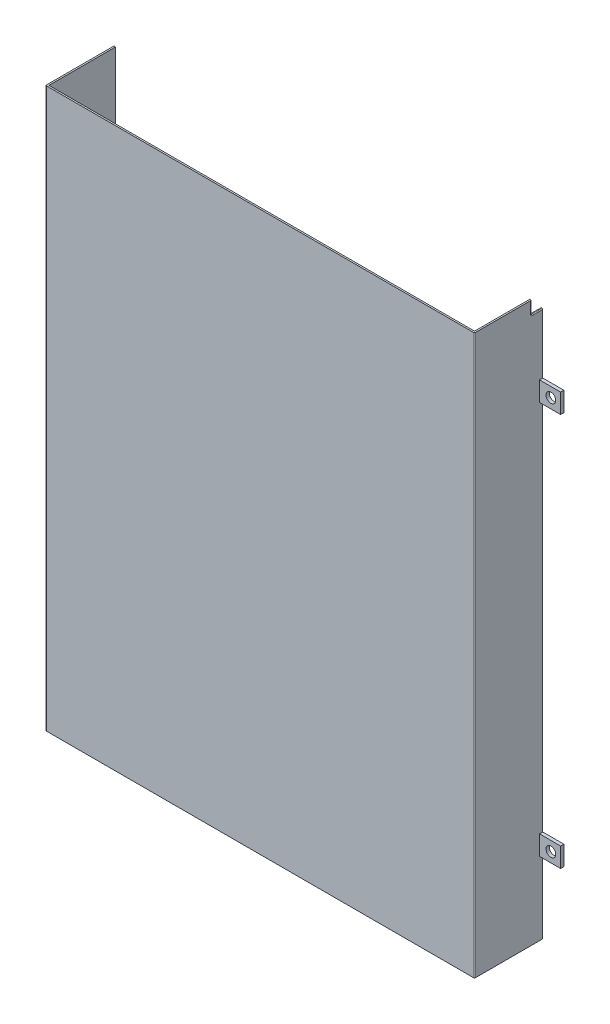
from build123d import *

# Parameters (mm, degrees)
WYCI_GNI_CIE_CIENKA_CIANKA1_DEPTH      = 172
WYCI_GNI_CIE_CIENKA_CIANKA1_DEPTH_BACK = 172
SZKIC2_W                               = 13
SZKIC2_H                               = 12
SZKIC2_R                               = 3
DODANIE_WYCI_GNI_CIE1_DEPTH            = 2
ZAOKR_GLENIE1_R                        = 0.5
WYTNIJ_WYCI_GNI_CIE2_DEPTH             = 14
WYTNIJ_WYCI_GNI_CIE2_DEPTH_BACK        = 2
ZAOKR_GLENIE4_R                        = 0.5
ZAOKR_GLENIE5_R                        = 0.5


with BuildPart() as part:
    # Szkic1 → Wyciągnięcie-cienka ścianka1 (new body, two sides)
    with BuildSketch(Plane(origin=(0, 0, 0), x_dir=(1, 0, 0), z_dir=(0, 1, 0))) as wyci_gni_cie_cienka_cianka1_sk:
        Polygon((211, -111), (211, -152), (-51, -152), (-51, -111), (-52, -111), (-52, -153), (212, -153), (212, -111), align=None)
    extrude(amount=WYCI_GNI_CIE_CIENKA_CIANKA1_DEPTH)
    extrude(wyci_gni_cie_cienka_cianka1_sk.sketch, amount=-WYCI_GNI_CIE_CIENKA_CIANKA1_DEPTH_BACK)

    # Szkic2 → Dodanie-wyciągnięcie1 (add)
    with BuildSketch(Plane(origin=(0, 0, 111), x_dir=(-1, 0, 0), z_dir=(0, 0, -1))):
        with Locations((-218.5, -121)):
            Rectangle(SZKIC2_W, SZKIC2_H)
        with Locations((-219, -121)):
            Circle(SZKIC2_R, mode=Mode.SUBTRACT)
        with Locations((-218.5, 121)):
            Rectangle(SZKIC2_W, SZKIC2_H)
        with Locations((-219, 121)):
            Circle(SZKIC2_R, mode=Mode.SUBTRACT)
    extrude(amount=-DODANIE_WYCI_GNI_CIE1_DEPTH)

    # Zaokrąglenie1
    zaokr_glenie1_edges = [part.edges().sort_by_distance(p)[0] for p in [
        (212, 0, 153),
        (-52, 0, 153),
    ]]
    fillet(zaokr_glenie1_edges, radius=ZAOKR_GLENIE1_R)

    # Szkic5 → Wytnij-wyciągnięcie2 (cut, two sides)
    with BuildSketch(Plane(origin=(212, 0, 0), x_dir=(0, 0, -1), z_dir=(1, 0, 0))) as wytnij_wyci_gni_cie2_sk:
        Polygon((-118, 873.551878025), (-118, 172), (-118, 164), (-111, 164), (590.551878025, 164), (1583.395439141, 1155.444306753), (874.843561116, 1864.996184778), align=None)
    extrude(amount=WYTNIJ_WYCI_GNI_CIE2_DEPTH, mode=Mode.SUBTRACT)
    extrude(wytnij_wyci_gni_cie2_sk.sketch, amount=-WYTNIJ_WYCI_GNI_CIE2_DEPTH_BACK, mode=Mode.SUBTRACT)

    # Zaokrąglenie4
    zaokr_glenie4_edges = [part.edges().sort_by_distance(p)[0] for p in [
        (211.5, 164, 118),
    ]]
    fillet(zaokr_glenie4_edges, radius=ZAOKR_GLENIE4_R)

    # Zaokrąglenie5
    zaokr_glenie5_edges = [part.edges().sort_by_distance(p)[0] for p in [
        (212, 164, 114.25),
        (212, 168.25, 118),
        (212, 164.146446609, 117.853553391),
    ]]
    fillet(zaokr_glenie5_edges, radius=ZAOKR_GLENIE5_R)


solid = part.part
